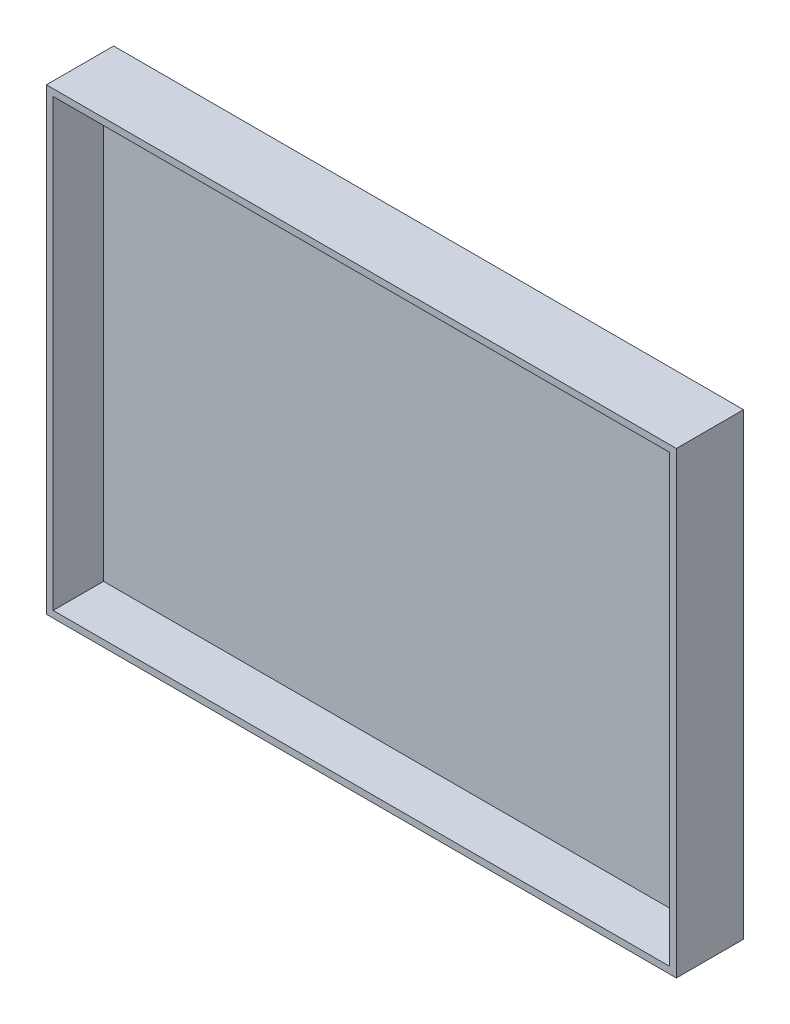
from build123d import *

# Parameters (mm, degrees)
ESQUISSE1_W        = 36.7
ESQUISSE1_H        = 26.5
BOSS_EXTRU_2_DEPTH = 1
ESQUISSE1_2_W      = 37.5
ESQUISSE1_2_H      = 27.3
ESQUISSE1_2_W_2    = 36.7
ESQUISSE1_2_H_2    = 26.5
EXTRU_MINCE1_DEPTH = 4


with BuildPart() as part:
    # Esquisse1 → Boss.-Extru.2 (new body)
    with BuildSketch(Plane.XY):
        Rectangle(ESQUISSE1_W, ESQUISSE1_H)
    extrude(amount=BOSS_EXTRU_2_DEPTH)

    # Esquisse1_2 → Extru.-Mince1 (add)
    with BuildSketch(Plane.XY):
        Rectangle(ESQUISSE1_2_W, ESQUISSE1_2_H)
        Rectangle(ESQUISSE1_2_W_2, ESQUISSE1_2_H_2, mode=Mode.SUBTRACT)
    extrude(amount=EXTRU_MINCE1_DEPTH)


solid = part.part
